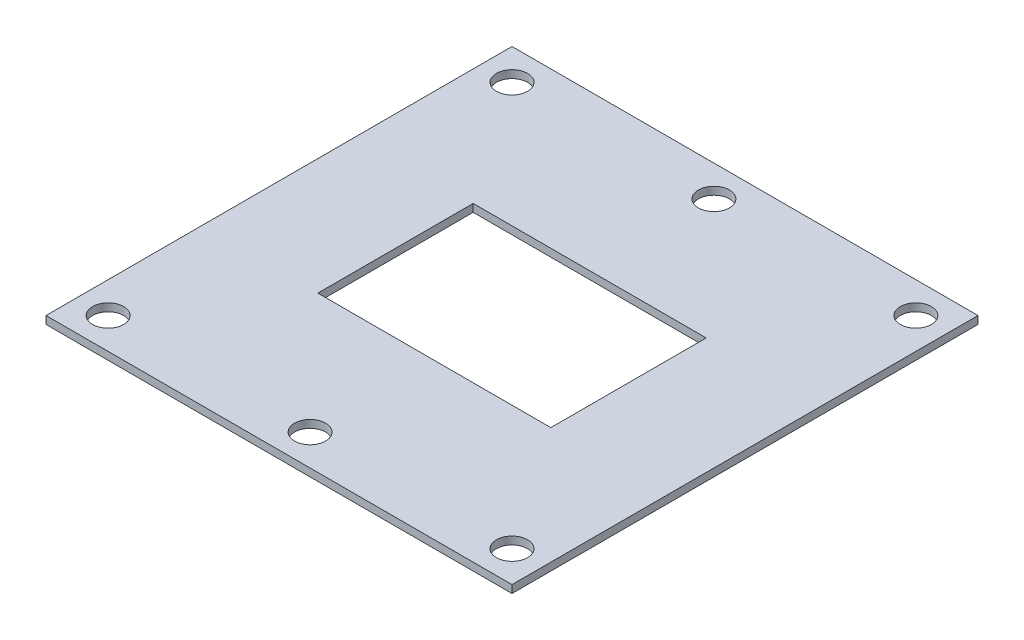
from build123d import *

# Parameters (mm, degrees)
SKETCH1_W                    = 60
SKETCH1_H                    = 60
BOSS_EXTRUDE1_DEPTH          = 1
F_4_0_4_DIAMETER_HOLE1_D     = 4
F_4_0_4_DIAMETER_HOLE1_DEPTH = 1
SKETCH14_W                   = 30
SKETCH14_H                   = 20
CUT_EXTRUDE1_DEPTH           = 10


with BuildPart() as part:
    # Sketch1 → Boss-Extrude1 (new body)
    with BuildSketch(Plane(origin=(0, 0, 0), x_dir=(1, 0, 0), z_dir=(0, 1, 0))):
        Rectangle(SKETCH1_W, SKETCH1_H)
    extrude(amount=BOSS_EXTRUDE1_DEPTH)

    # Ø4.0 (4) Diameter Hole1
    with Locations(Plane(origin=(0, 1, 0), x_dir=(1, 0, 0), z_dir=(0, 1, 0))):
        with Locations((26, 26), (0, 26), (-26, 26), (0, -26), (26, -26), (-26, -26)):
            Hole(F_4_0_4_DIAMETER_HOLE1_D / 2, depth=F_4_0_4_DIAMETER_HOLE1_DEPTH)

    # Sketch14 → Cut-Extrude1 (cut)
    with BuildSketch(Plane(origin=(0, 1, 0), x_dir=(1, 0, 0), z_dir=(0, 1, 0))):
        Rectangle(SKETCH14_W, SKETCH14_H)
    extrude(amount=-CUT_EXTRUDE1_DEPTH, mode=Mode.SUBTRACT)


solid = part.part
